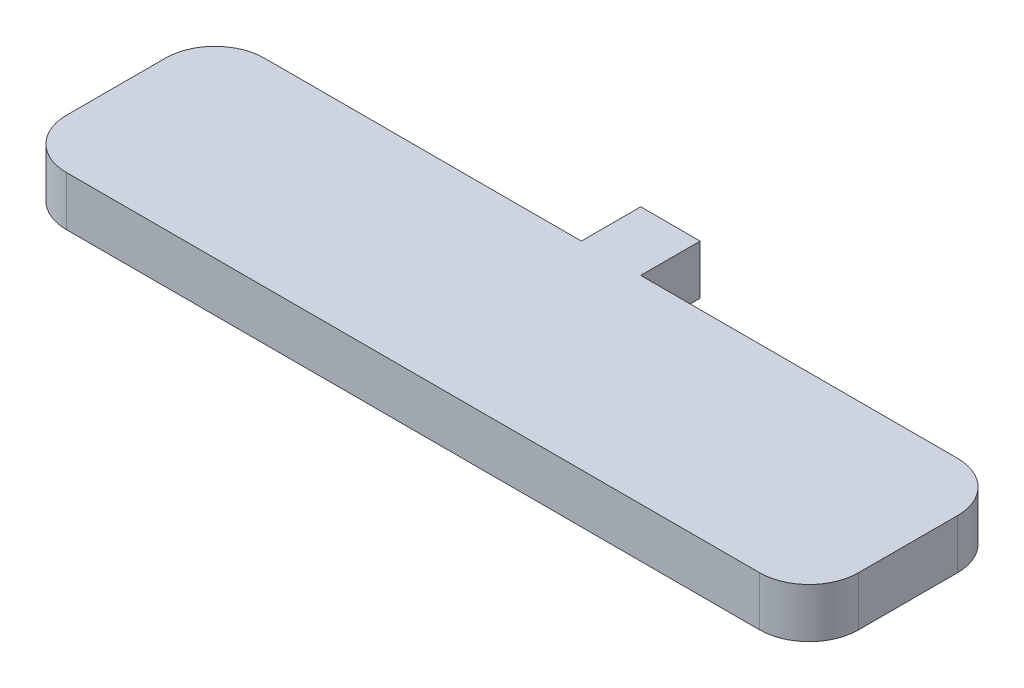
from build123d import *

# Parameters (mm, degrees)
SKETCH1_W           = 80
SKETCH1_H           = 20
BOSS_EXTRUDE1_DEPTH = 5
FILLET1_R           = 5
SHELL1_T            = -2
SKETCH2_W           = 6
SKETCH2_H           = 5
BOSS_EXTRUDE2_DEPTH = 6
SKETCH3_R           = 1.425
CUT_EXTRUDE2_DEPTH  = 4


with BuildPart() as part:
    # Sketch1 → Boss-Extrude1 (new body)
    with BuildSketch(Plane(origin=(0, 0, 0), x_dir=(1, 0, 0), z_dir=(0, 1, 0))):
        Rectangle(SKETCH1_W, SKETCH1_H)
    extrude(amount=BOSS_EXTRUDE1_DEPTH)

    # Fillet1
    fillet1_edges = [part.edges().sort_by_distance(p)[0] for p in [
        (-40, 2.5, -10),
        (40, 2.5, -10),
        (40, 2.5, 10),
        (-40, 2.5, 10),
    ]]
    fillet(fillet1_edges, radius=FILLET1_R)

    # Shell1
    shell1_openings = [part.faces().sort_by_distance(p)[0] for p in [
        (0, 0, 0),
    ]]
    offset(amount=SHELL1_T, openings=shell1_openings, kind=Kind.INTERSECTION)

    # Sketch2 → Boss-Extrude2 (add)
    with BuildSketch(Plane(origin=(0, 0, -10), x_dir=(-1, 0, 0), z_dir=(0, 0, -1))):
        with Locations((0, 2.5)):
            Rectangle(SKETCH2_W, SKETCH2_H)
    extrude(amount=BOSS_EXTRUDE2_DEPTH)

    # Sketch3 → Cut-Extrude2 (cut)
    with BuildSketch(Plane(origin=(0, 0, -16), x_dir=(-1, 0, 0), z_dir=(0, 0, -1))):
        with Locations((0, 2.5)):
            Circle(SKETCH3_R)
    extrude(amount=-CUT_EXTRUDE2_DEPTH, mode=Mode.SUBTRACT)


solid = part.part
